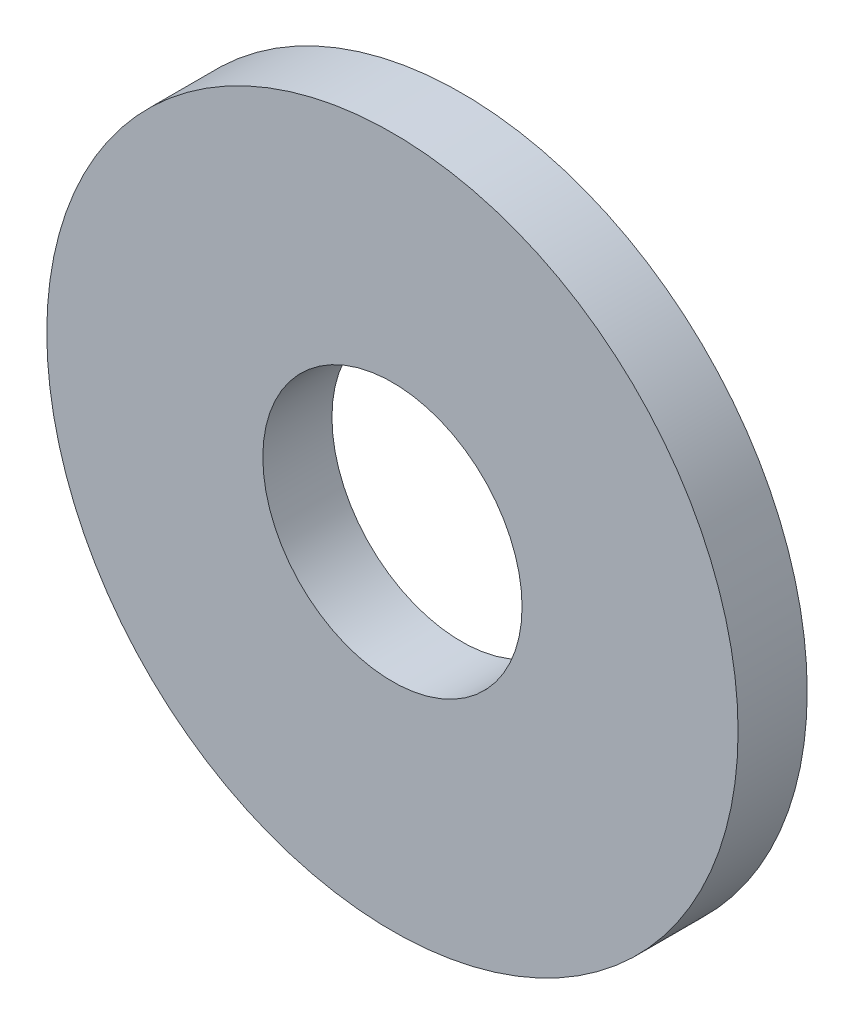
from build123d import *

# Parameters (mm, degrees)
ESQUISSE1_R        = 4
ESQUISSE1_R_2      = 1.5
BOSS_EXTRU_1_DEPTH = 0.8


with BuildPart() as part:
    # Esquisse1 → Boss.-Extru.1 (new body)
    with BuildSketch(Plane.XY):
        Circle(ESQUISSE1_R)
        Circle(ESQUISSE1_R_2, mode=Mode.SUBTRACT)
    extrude(amount=BOSS_EXTRU_1_DEPTH)


solid = part.part
